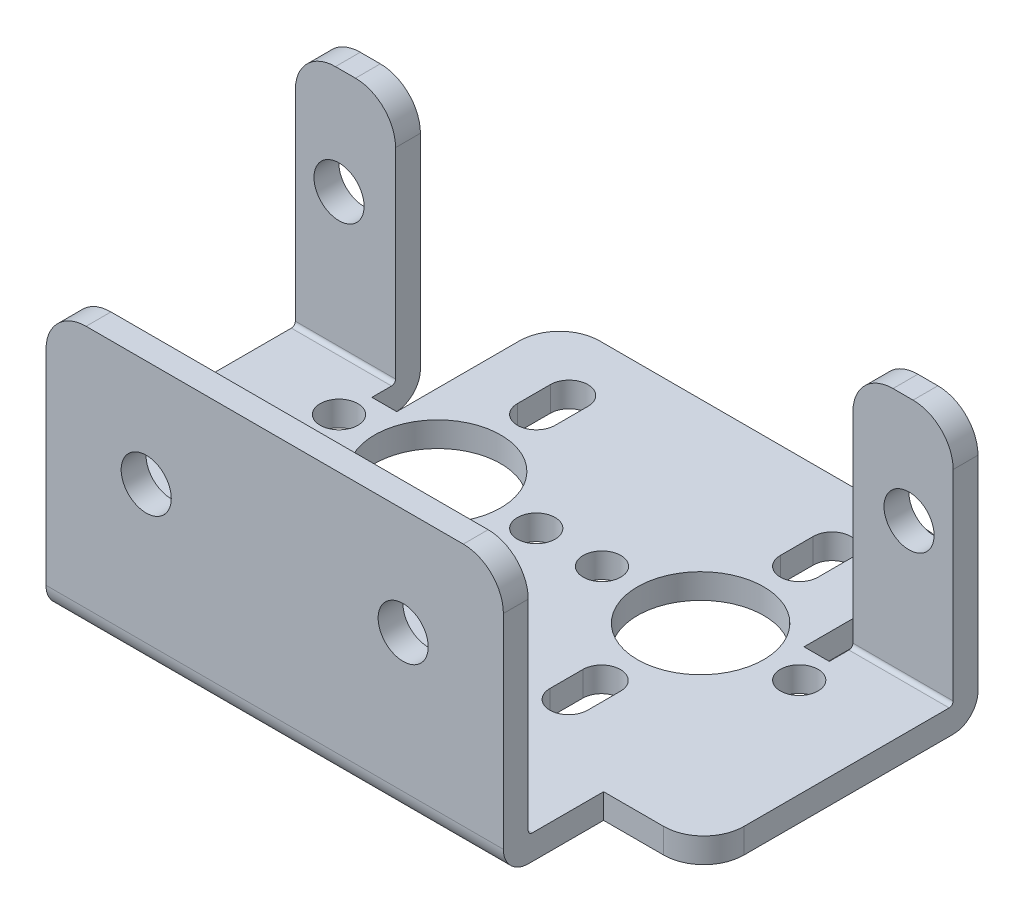
from build123d import *

# Parameters (mm, degrees)
SKETCH1_W         = 30.9626
SKETCH1_H         = 17.0688
EXTRUDE1_DEPTH    = 41.6814
SKETCH3_OUTSIDE_W = 43.895
SKETCH3_OUTSIDE_H = 30.001
EXTRUDE2_DEPTH    = 42.6814
SKETCH4_W         = 6.35
SKETCH4_H         = 17.0688
EXTRUDE3_DEPTH    = 6.35
SKETCH5_W         = 6.35
SKETCH5_H         = 7.239
EXTRUDE4_DEPTH    = 1.5748
SKETCH6_W         = 28.9814
SKETCH6_H         = 15.494
EXTRUDE5_DEPTH    = 1.5748
SKETCH7_W         = 1.6002
SKETCH7_H         = 1.5748
SKETCH7_W_2       = 1.5748
EXTRUDE6_DEPTH    = 10.3124
FILLET1_R         = 1.5875
FILLET2_R         = 0.254
SKETCH8_R         = 4.0005
SKETCH8_R_2       = 1.1938
EXTRUDE7_DEPTH    = 1.5748
SKETCH9_R         = 1.5875
EXTRUDE9_DEPTH    = 31.9626
FILLET3_R         = 2.54


with BuildPart() as part:
    # Sketch1 → Extrude1 (new body)
    with BuildSketch(Plane(origin=(0, 0, 0), x_dir=(0, 0, -1), z_dir=(1, 0, 0))):
        with Locations((15.4813, 8.5344)):
            Rectangle(SKETCH1_W, SKETCH1_H)
    extrude(amount=EXTRUDE1_DEPTH)

    # Sketch3 outside → Extrude2 (cut, through all)
    with BuildSketch(Plane(origin=(41.6814, 0, 0), x_dir=(0, 0, -1), z_dir=(1, 0, 0))):
        with Locations((15.4815, 8.5345)):
            Rectangle(SKETCH3_OUTSIDE_W, SKETCH3_OUTSIDE_H)
        Polygon((0, 17.0688), (0, 0), (30.9626, 0), (30.9626, 1.5748), (23.7236, 1.5748), (23.7236, 17.0688), (22.1488, 17.0688), (22.1488, 1.5748), (1.5748, 1.5748), (1.5748, 17.0688), align=None, mode=Mode.SUBTRACT)
    extrude(amount=-EXTRUDE2_DEPTH, mode=Mode.SUBTRACT)

    # Sketch4 → Extrude3 (cut)
    with BuildSketch(Plane.XY):
        with Locations((3.175, 8.5344)):
            Rectangle(SKETCH4_W, SKETCH4_H)
        with Locations((38.5064, 8.5344)):
            Rectangle(SKETCH4_W, SKETCH4_H)
    extrude(amount=-EXTRUDE3_DEPTH, mode=Mode.SUBTRACT)

    # Sketch5 → Extrude4 (cut)
    with BuildSketch(Plane(origin=(0, 1.5748, 0), x_dir=(1, 0, 0), z_dir=(0, 1, 0))):
        with Locations((3.175, 27.3431)):
            Rectangle(SKETCH5_W, SKETCH5_H)
        with Locations((38.5064, 27.3431)):
            Rectangle(SKETCH5_W, SKETCH5_H)
    extrude(amount=-EXTRUDE4_DEPTH, mode=Mode.SUBTRACT)

    # Sketch6 → Extrude5 (cut)
    with BuildSketch(Plane(origin=(0, 0, -23.7236), x_dir=(-1, 0, 0), z_dir=(0, 0, -1))):
        with Locations((-20.8407, 9.3218)):
            Rectangle(SKETCH6_W, SKETCH6_H)
    extrude(amount=-EXTRUDE5_DEPTH, mode=Mode.SUBTRACT)

    # Sketch7 → Extrude6 (cut)
    with BuildSketch(Plane(origin=(0, 0, -30.9626), x_dir=(-1, 0, 0), z_dir=(0, 0, -1))):
        with Locations((-34.5313, 0.7874)):
            Rectangle(SKETCH7_W, SKETCH7_H)
        with Locations((-7.1374, 0.7874)):
            Rectangle(SKETCH7_W_2, SKETCH7_H)
    extrude(amount=-EXTRUDE6_DEPTH, mode=Mode.SUBTRACT)

    # Fillet1
    fillet1_edges = [part.edges().sort_by_distance(p)[0] for p in [
        (3.175, 0, -23.7236),
        (38.5064, 0, -23.7236),
        (20.8407, 0, 0),
    ]]
    fillet(fillet1_edges, radius=FILLET1_R)

    # Fillet2
    fillet2_edges = [part.edges().sort_by_distance(p)[0] for p in [
        (38.5064, 1.5748, -22.1488),
        (3.175, 1.5748, -22.1488),
        (20.8407, 1.5748, -1.5748),
    ]]
    fillet(fillet2_edges, radius=FILLET2_R)

    # Sketch8 → Extrude7 (cut)
    with BuildSketch(Plane(origin=(0, 1.5748, 0), x_dir=(1, 0, 0), z_dir=(0, 1, 0))):
        with Locations(Location((12.4968, 18.669, 0), (0, 0, 270))):  # turned: the seam where the file's is
            Circle(SKETCH8_R)
        with Locations(Location((18.7452, 18.669, 0), (0, 0, 270))):  # turned: the seam where the file's is
            Circle(SKETCH8_R_2)
        with Locations(Location((6.2484, 18.669, 0), (0, 0, 270))):  # turned: the seam where the file's is
            Circle(SKETCH8_R_2)
        with Locations(Location((22.9108, 18.669, 0), (0, 0, 270))):  # turned: the seam where the file's is
            Circle(SKETCH8_R_2)
        with Locations(Location((29.1592, 18.669, 0), (0, 0, 270))):  # turned: the seam where the file's is
            Circle(SKETCH8_R)
        with Locations(Location((35.4076, 18.669, 0), (0, 0, 270))):  # turned: the seam where the file's is
            Circle(SKETCH8_R_2)
        with BuildLine():
            Line((13.6906, 27.0002), (13.6906, 24.9174))
            ThreePointArc((13.6906, 24.9174), (12.4968, 23.7236), (11.303, 24.9174))
            Line((11.303, 24.9174), (11.303, 27.0002))
            ThreePointArc((11.303, 27.0002), (12.4968, 28.194), (13.6906, 27.0002))
        make_face()
        with BuildLine():
            Line((13.6906, 12.3952), (13.6906, 10.3124))
            ThreePointArc((13.6906, 10.3124), (12.4968, 9.1186), (11.303, 10.3124))
            Line((11.303, 10.3124), (11.303, 12.3952))
            ThreePointArc((11.303, 12.3952), (12.4968, 13.589), (13.6906, 12.3952))
        make_face()
        with BuildLine():
            Line((27.9654, 12.3952), (27.9654, 10.3124))
            ThreePointArc((27.9654, 10.3124), (29.1592, 9.1186), (30.353, 10.3124))
            Line((30.353, 10.3124), (30.353, 12.3952))
            ThreePointArc((30.353, 12.3952), (29.1592, 13.589), (27.9654, 12.3952))
        make_face()
        with BuildLine():
            Line((27.9654, 27.0002), (27.9654, 24.9174))
            ThreePointArc((27.9654, 24.9174), (29.1592, 23.7236), (30.353, 24.9174))
            Line((30.353, 24.9174), (30.353, 27.0002))
            ThreePointArc((30.353, 27.0002), (29.1592, 28.194), (27.9654, 27.0002))
        make_face()
    extrude(amount=-EXTRUDE7_DEPTH, mode=Mode.SUBTRACT)

    # Sketch9 → Extrude9 (cut, through all)
    with BuildSketch(Plane.XY):
        with Locations(Location((2.7686, 10.3124, 0), (0, 0, 270))):  # turned: the seam where the file's is
            Circle(SKETCH9_R)
        with Locations((12.7, 10.3124)):
            Circle(SKETCH9_R)
        with Locations((28.9814, 10.3124)):
            Circle(SKETCH9_R)
        with Locations(Location((38.8874, 10.3124, 0), (0, 0, 270))):  # turned: the seam where the file's is
            Circle(SKETCH9_R)
    extrude(amount=-EXTRUDE9_DEPTH, mode=Mode.SUBTRACT)

    # Fillet3
    fillet3_edges = [part.edges().sort_by_distance(p)[0] for p in [
        (6.35, 17.0688, -22.9362),
        (35.3314, 17.0688, -22.9362),
        (0, 17.0688, -22.9362),
        (33.7312, 0.7874, -30.9626),
        (7.9248, 0.7874, -30.9626),
        (41.6814, 17.0688, -22.9362),
        (0, 0.7874, -6.35),
        (6.35, 17.0688, -0.7874),
        (35.3314, 17.0688, -0.7874),
        (41.6814, 0.7874, -6.35),
    ]]
    fillet(fillet3_edges, radius=FILLET3_R)


solid = part.part
